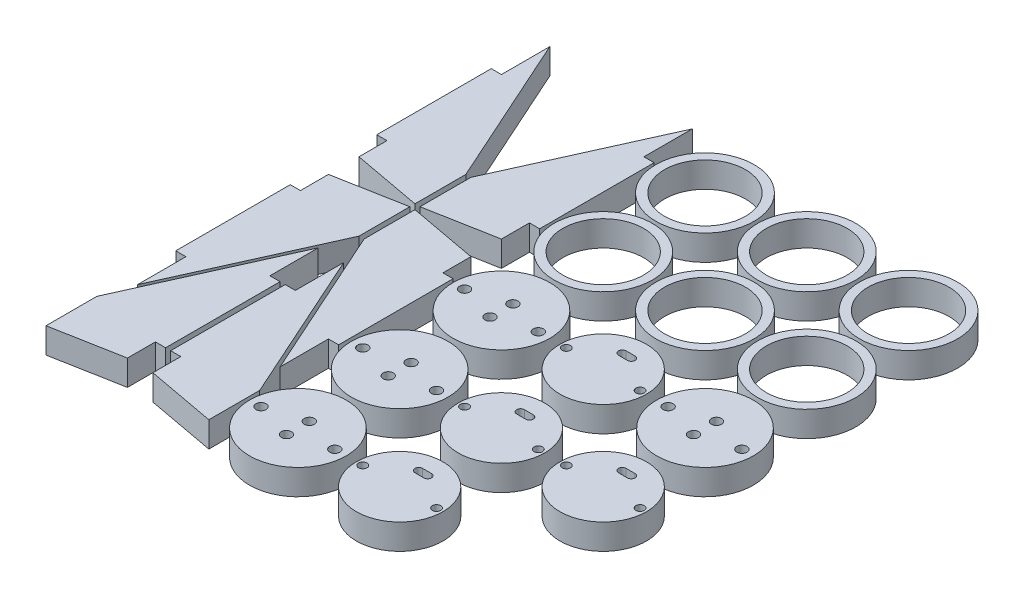
from build123d import *

# Parameters (mm, degrees)
SKETCH1_W           = 450
SKETCH1_H           = 300
BOSS_EXTRUDE1_DEPTH = 10
SKETCH3_W           = 450
SKETCH3_H           = 300
SKETCH3_R           = 19.305
SKETCH3_R_2         = 19
SKETCH3_R_3         = 17
SKETCH3_R_4         = 15.9
SKETCH3_R_5         = 2
SKETCH3_R_6         = 1.65
CUT_EXTRUDE1_DEPTH  = 10


with BuildPart() as part:
    # Sketch1 → Boss-Extrude1 (new body)
    with BuildSketch(Plane(origin=(0, 0, 0), x_dir=(1, 0, 0), z_dir=(0, 1, 0))):
        Rectangle(SKETCH1_W, SKETCH1_H)
    extrude(amount=BOSS_EXTRUDE1_DEPTH)

    # Sketch3 → Cut-Extrude1 (cut)
    with BuildSketch(Plane(origin=(0, 10, 0), x_dir=(1, 0, 0), z_dir=(0, 1, 0))):
        Rectangle(SKETCH3_W, SKETCH3_H)
        Polygon((-216, 126), (-216, 145), (-189, 85), (-189, 65), (-216, 70), (-216, 81), (-220, 81), (-220, 126), align=None, mode=Mode.SUBTRACT)
        Polygon((-220, 2), (-220, 47), (-216, 47), (-216, 58), (-189, 63), (-189, 43), (-216, -17), (-216, 2), align=None, mode=Mode.SUBTRACT)
        Polygon((-220, -49), (-220, -29), (-193, 31), (-193, 12), (-189, 12), (-189, -33), (-193, -33), (-193, -44), align=None, mode=Mode.SUBTRACT)
        Polygon((-156, 126), (-156, 81), (-160, 81), (-160, 70), (-187, 65), (-187, 85), (-160, 145), (-160, 126), align=None, mode=Mode.SUBTRACT)
        with Locations(Location((-135.695, 125.695, 0), (0, 0, 270))):
            Circle(SKETCH3_R, mode=Mode.SUBTRACT)
        with Locations(Location((-95.695, 85.695, 0), (0, 0, 270))):
            Circle(SKETCH3_R, mode=Mode.SUBTRACT)
        with Locations(Location((-55.695, 85.695, 0), (0, 0, 270))):
            Circle(SKETCH3_R, mode=Mode.SUBTRACT)
        with Locations(Location((-95.695, 125.695, 0), (0, 0, 270))):
            Circle(SKETCH3_R, mode=Mode.SUBTRACT)
        with Locations(Location((-55.695, 125.695, 0), (0, 0, 270))):
            Circle(SKETCH3_R, mode=Mode.SUBTRACT)
        Polygon((-183, -44), (-183, -33), (-187, -33), (-187, 12), (-183, 12), (-183, 31), (-156, -29), (-156, -49), align=None, mode=Mode.SUBTRACT)
        with Locations(Location((-135.695, -34.305, 0), (0, 0, 270))):
            Circle(SKETCH3_R_2, mode=Mode.SUBTRACT)
        Polygon((-160, -17), (-187, 43), (-187, 63), (-160, 58), (-160, 47), (-156, 47), (-156, 2), (-160, 2), align=None, mode=Mode.SUBTRACT)
        with Locations(Location((-135.695, 5.695, 0), (0, 0, 270))):
            Circle(SKETCH3_R_2, mode=Mode.SUBTRACT)
        with Locations(Location((-135.695, 45.695, 0), (0, 0, 270))):
            Circle(SKETCH3_R_2, mode=Mode.SUBTRACT)
        with Locations(Location((-95.695, -34.305, 0), (0, 0, 270))):
            Circle(SKETCH3_R_3, mode=Mode.SUBTRACT)
        with Locations(Location((-95.695, 5.695, 0), (0, 0, 270))):
            Circle(SKETCH3_R_3, mode=Mode.SUBTRACT)
        with Locations(Location((-95.695, 45.695, 0), (0, 0, 270))):
            Circle(SKETCH3_R_3, mode=Mode.SUBTRACT)
        with Locations(Location((-55.695, 5.695, 0), (0, 0, 270))):
            Circle(SKETCH3_R_3, mode=Mode.SUBTRACT)
        with Locations(Location((-55.695, 45.695, 0), (0, 0, 270))):
            Circle(SKETCH3_R_2, mode=Mode.SUBTRACT)
        with Locations(Location((-135.695, 85.695, 0), (0, 0, 270))):
            Circle(SKETCH3_R, mode=Mode.SUBTRACT)
        with BuildLine():
            Line((-93.945, 56.445), (-97.445, 56.445))
            ThreePointArc((-97.445, 56.445), (-98.945, 54.945), (-97.445, 53.445))
            Line((-97.445, 53.445), (-93.945, 53.445))
            ThreePointArc((-93.945, 53.445), (-92.445, 54.945), (-93.945, 56.445))
        make_face()
        with BuildLine():
            Line((-93.945, 16.445), (-97.445, 16.445))
            ThreePointArc((-97.445, 16.445), (-98.945, 14.945), (-97.445, 13.445))
            Line((-97.445, 13.445), (-93.945, 13.445))
            ThreePointArc((-93.945, 13.445), (-92.445, 14.945), (-93.945, 16.445))
        make_face()
        with BuildLine():
            Line((-93.945, -23.555), (-97.445, -23.555))
            ThreePointArc((-97.445, -23.555), (-98.945, -25.055), (-97.445, -26.555))
            Line((-97.445, -26.555), (-93.945, -26.555))
            ThreePointArc((-93.945, -26.555), (-92.445, -25.055), (-93.945, -23.555))
        make_face()
        with BuildLine():
            Line((-53.945, 16.445), (-57.445, 16.445))
            ThreePointArc((-57.445, 16.445), (-58.945, 14.945), (-57.445, 13.445))
            Line((-57.445, 13.445), (-53.945, 13.445))
            ThreePointArc((-53.945, 13.445), (-52.445, 14.945), (-53.945, 16.445))
        make_face()
        with Locations(Location((-135.695, 125.695, 0), (0, 0, 270))):
            Circle(SKETCH3_R_4)
        with Locations(Location((-95.695, 125.695, 0), (0, 0, 270))):
            Circle(SKETCH3_R_4)
        with Locations(Location((-95.695, 85.695, 0), (0, 0, 270))):
            Circle(SKETCH3_R_4)
        with Locations(Location((-135.695, 85.695, 0), (0, 0, 270))):
            Circle(SKETCH3_R_4)
        with Locations(Location((-121.195, 45.695, 0), (0, 0, 270))):
            Circle(SKETCH3_R_5)
        with Locations(Location((-150.195, 45.695, 0), (0, 0, 270))):
            Circle(SKETCH3_R_5)
        with Locations(Location((-135.695, 50.195, 0), (0, 0, 270))):
            Circle(SKETCH3_R_5)
        with Locations(Location((-135.695, 41.195, 0), (0, 0, 270))):
            Circle(SKETCH3_R_5)
        with Locations(Location((-81.195, 45.695, 0), (0, 0, 270))):
            Circle(SKETCH3_R_6)
        with Locations(Location((-110.195, 45.695, 0), (0, 0, 270))):
            Circle(SKETCH3_R_6)
        with Locations(Location((-55.695, 125.695, 0), (0, 0, 270))):
            Circle(SKETCH3_R_4)
        with Locations(Location((-55.695, 85.695, 0), (0, 0, 270))):
            Circle(SKETCH3_R_4)
        with Locations(Location((-135.695, 1.195, 0), (0, 0, 270))):
            Circle(SKETCH3_R_5)
        with Locations(Location((-150.195, 5.695, 0), (0, 0, 270))):
            Circle(SKETCH3_R_5)
        with Locations(Location((-121.195, 5.695, 0), (0, 0, 270))):
            Circle(SKETCH3_R_5)
        with Locations(Location((-135.695, 10.195, 0), (0, 0, 270))):
            Circle(SKETCH3_R_5)
        with Locations(Location((-110.195, 5.695, 0), (0, 0, 270))):
            Circle(SKETCH3_R_6)
        with Locations(Location((-81.195, 5.695, 0), (0, 0, 270))):
            Circle(SKETCH3_R_6)
        with Locations(Location((-135.695, -38.805, 0), (0, 0, 270))):
            Circle(SKETCH3_R_5)
        with Locations(Location((-150.195, -34.305, 0), (0, 0, 270))):
            Circle(SKETCH3_R_5)
        with Locations(Location((-121.195, -34.305, 0), (0, 0, 270))):
            Circle(SKETCH3_R_5)
        with Locations(Location((-135.695, -29.805, 0), (0, 0, 270))):
            Circle(SKETCH3_R_5)
        with Locations(Location((-110.195, -34.305, 0), (0, 0, 270))):
            Circle(SKETCH3_R_6)
        with Locations(Location((-81.195, -34.305, 0), (0, 0, 270))):
            Circle(SKETCH3_R_6)
        with Locations(Location((-55.695, 50.195, 0), (0, 0, 270))):
            Circle(SKETCH3_R_5)
        with Locations(Location((-41.195, 45.695, 0), (0, 0, 270))):
            Circle(SKETCH3_R_5)
        with Locations(Location((-55.695, 41.195, 0), (0, 0, 270))):
            Circle(SKETCH3_R_5)
        with Locations(Location((-70.195, 45.695, 0), (0, 0, 270))):
            Circle(SKETCH3_R_5)
        with Locations(Location((-41.195, 5.695, 0), (0, 0, 270))):
            Circle(SKETCH3_R_6)
        with Locations(Location((-70.195, 5.695, 0), (0, 0, 270))):
            Circle(SKETCH3_R_6)
    extrude(amount=-CUT_EXTRUDE1_DEPTH, mode=Mode.SUBTRACT)


solid = part.part
